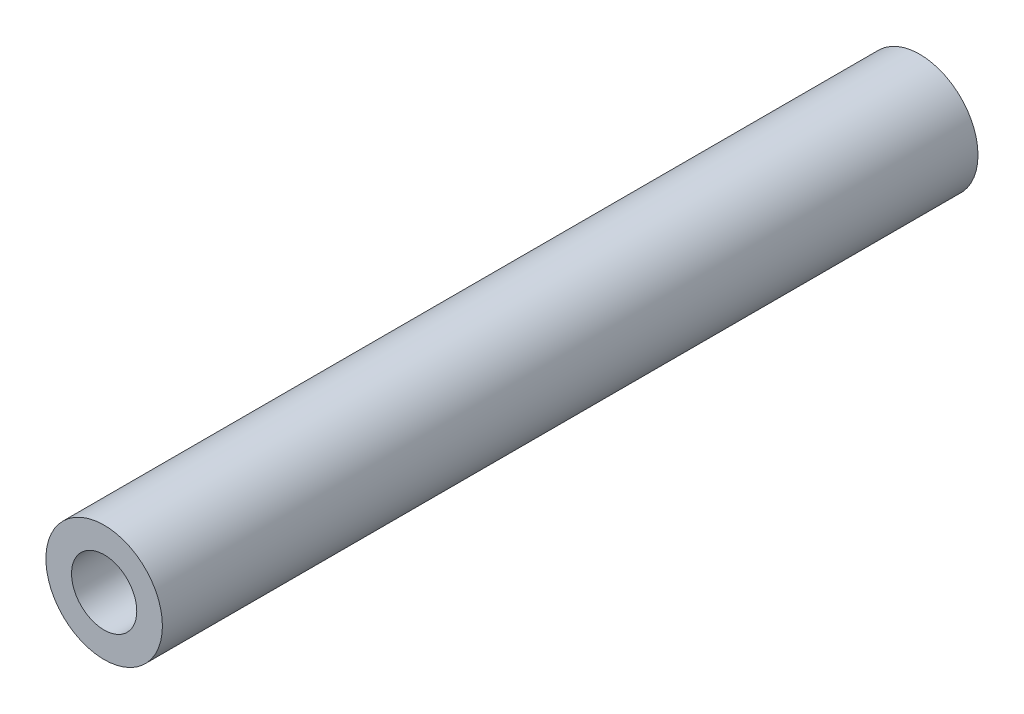
from build123d import *

# Parameters (mm, degrees)
SKETCH1_R           = 3.175
SKETCH1_R_2         = 1.778
BOSS_EXTRUDE1_DEPTH = 44.45


with BuildPart() as part:
    # Sketch1 → Boss-Extrude1 (new body)
    with BuildSketch(Plane.XY):
        Circle(SKETCH1_R)
        Circle(SKETCH1_R_2, mode=Mode.SUBTRACT)
    extrude(amount=BOSS_EXTRUDE1_DEPTH)


solid = part.part
